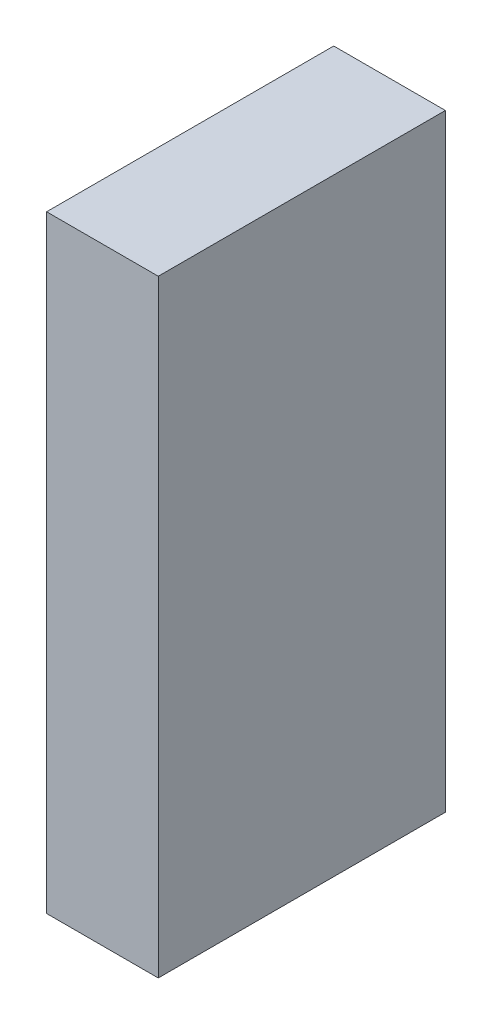
from build123d import *

# Parameters (mm, degrees)
SKETCH1_W           = 18
SKETCH1_H           = 38.1
BOSS_EXTRUDE1_DEPTH = 7


with BuildPart() as part:
    # Sketch1 → Boss-Extrude1 (new body)
    with BuildSketch(Plane(origin=(0, 0, 0), x_dir=(0, 0, -1), z_dir=(1, 0, 0))):
        with Locations((9, 19.05)):
            Rectangle(SKETCH1_W, SKETCH1_H)
    extrude(amount=BOSS_EXTRUDE1_DEPTH)


solid = part.part
